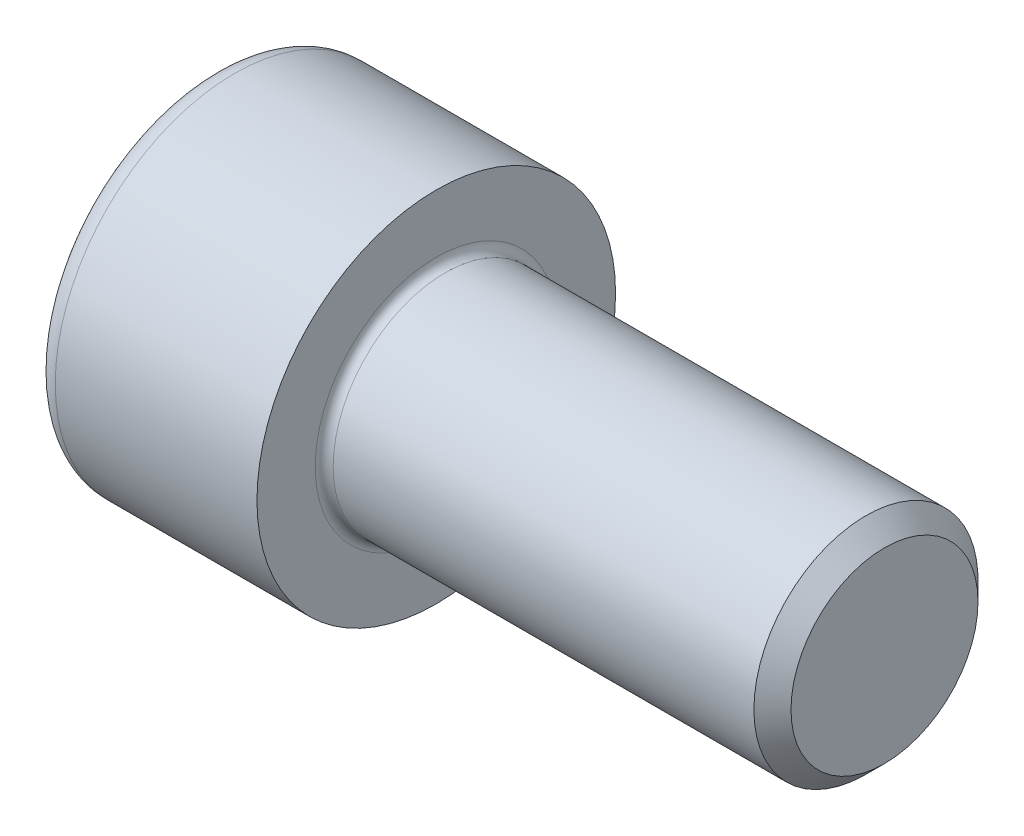
from build123d import *

# Parameters (mm, degrees)
FILLET1_R   = 0.4
FILLET2_R   = 1
HEX_2_DEPTH = 5


with BuildPart() as part:
    # BodySke → Base-Revolve (revolve)
    with BuildSketch(Plane.XY):
        Polygon((0, 0), (0, 8), (10, 8), (10, 5), (29.172, 5), (30, 4.172), (30, 0), align=None)
    revolve(axis=Axis((-31.75, 0, 0), (1, 0, 0)))

    # Fillet1
    fillet1_edges = [part.edges().sort_by_distance(p)[0] for p in [
        (10, -5, 0),
    ]]
    fillet(fillet1_edges, radius=FILLET1_R)

    # Fillet2
    fillet2_edges = [part.edges().sort_by_distance(p)[0] for p in [
        (0, -8, 0),
    ]]
    fillet(fillet2_edges, radius=FILLET2_R)

    # Sketch2 → Hex-PreBroach (revolve, cut)
    with BuildSketch(Plane.XY):
        Polygon((0, 4.0125), (5, 4.0125), (7.316617955, 0), (0, 0), align=None)
    revolve(axis=Axis((0, 0, 0), (1, 0, 0)), mode=Mode.SUBTRACT)

    # Sketch3 → Hex 2 (cut)
    with BuildSketch(Plane(origin=(0, 0, 0), x_dir=(0, 0.5, 0.866025404), z_dir=(-1, 0, 0))):
        Polygon((2.316617955, 4.0125), (-2.316617955, 4.0125), (-4.63323591, 0), (-2.316617955, -4.0125), (2.316617955, -4.0125), (4.63323591, 0), align=None)
    extrude(amount=-HEX_2_DEPTH, mode=Mode.SUBTRACT)


solid = part.part
